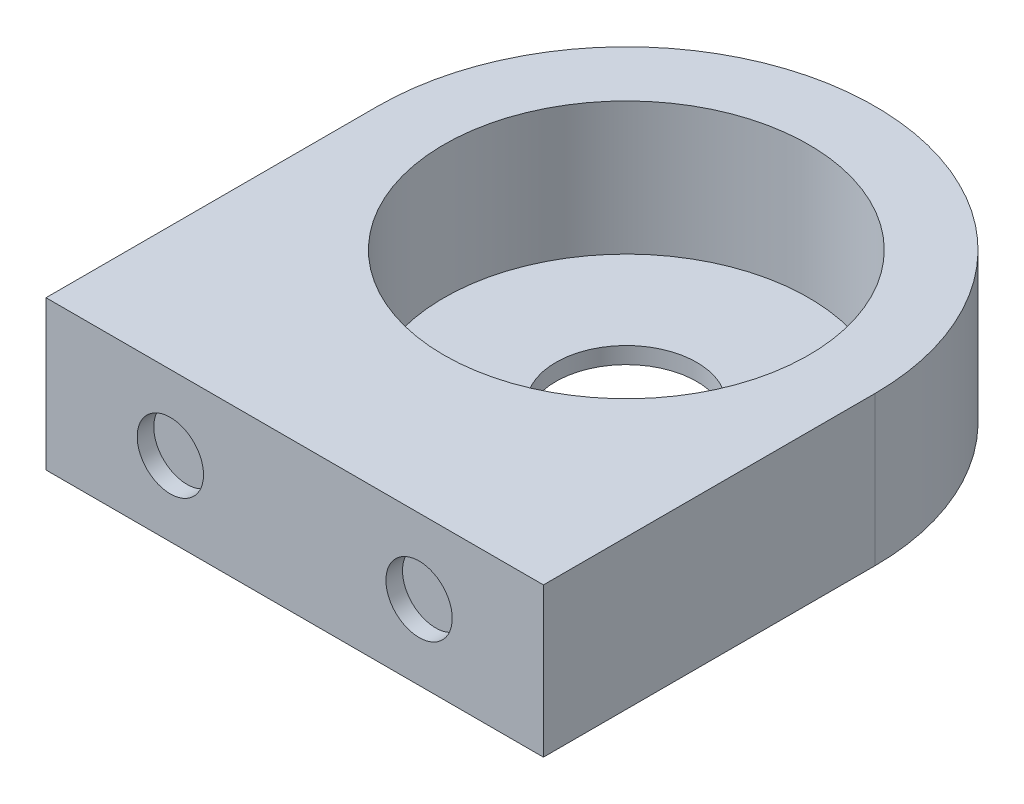
from build123d import *

# Parameters (mm, degrees)
SKETCH1_R           = 11
SKETCH1_R_2         = 4.25
BOSS_EXTRUDE1_DEPTH = 9
SKETCH2_R           = 11
CUT_EXTRUDE1_DEPTH  = 8
SKETCH4_R           = 2
CUT_EXTRUDE2_DEPTH  = 1


with BuildPart() as part:
    # Sketch1 → Boss-Extrude1 (new body)
    with BuildSketch(Plane(origin=(0, 0, 0), x_dir=(1, 0, 0), z_dir=(0, 1, 0))):
        with BuildLine():
            Line((30, 0), (30, 20))
            ThreePointArc((30, 20), (15, 35), (0, 20))
            Line((0, 20), (0, 0))
            Line((0, 0), (30, 0))
        make_face()
        with Locations((15, 20)):
            Circle(SKETCH1_R, mode=Mode.SUBTRACT)
        with Locations((15, 20)):
            Circle(SKETCH1_R)
        with Locations((15, 20)):
            Circle(SKETCH1_R_2, mode=Mode.SUBTRACT)
    extrude(amount=BOSS_EXTRUDE1_DEPTH)

    # Sketch2 → Cut-Extrude1 (cut)
    with BuildSketch(Plane(origin=(0, 9, 0), x_dir=(1, 0, 0), z_dir=(0, 1, 0))):
        with Locations((15, 20)):
            Circle(SKETCH2_R)
    extrude(amount=-CUT_EXTRUDE1_DEPTH, mode=Mode.SUBTRACT)

    # Sketch4 → Cut-Extrude2 (cut)
    with BuildSketch(Plane.XY):
        with Locations((7.5, 4.5)):
            Circle(SKETCH4_R)
        with Locations((22.5, 4.5)):
            Circle(SKETCH4_R)
    extrude(amount=-CUT_EXTRUDE2_DEPTH, mode=Mode.SUBTRACT)


solid = part.part
